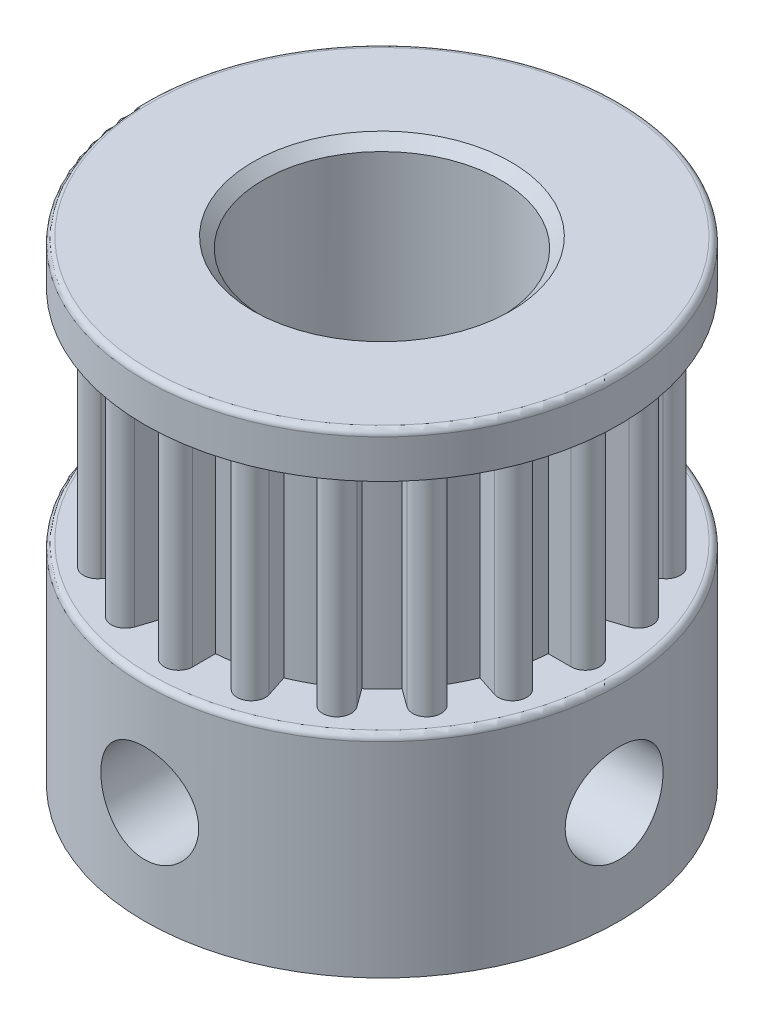
from build123d import *

# Parameters (mm, degrees)
SKETCH1_R           = 8
SKETCH1_R_2         = 6.11
SKETCH1_R_3         = 4
BOSS_EXTRUDE1_DEPTH = 7.1
SKETCH1_3_R         = 6.11
SKETCH1_3_R_2       = 4
BOSS_EXTRUDE2_DEPTH = 7.4
BOSS_EXTRUDE3_DEPTH = 7.4
SKETCH3_R           = 8
SKETCH3_R_2         = 4
BOSS_EXTRUDE4_DEPTH = 1.5
FILLET2_R           = 0.2
CHAMFER2_SIZE       = 0.35
CUT_EXTRUDE2_START  = -9.0000001
SKETCH5_R           = 1.65
CUT_EXTRUDE2_DEPTH  = 18.0000001
CIRPATTERN1_COUNT   = 2
CIRPATTERN1_ANGLE   = 90


with BuildPart() as part:
    # Sketch1 → Boss-Extrude1 (new body)
    with BuildSketch(Plane(origin=(0, 0, 0), x_dir=(1, 0, 0), z_dir=(0, 1, 0))):
        Circle(SKETCH1_R)
        Circle(SKETCH1_R_2, mode=Mode.SUBTRACT)
        Circle(SKETCH1_R_2)
        Circle(SKETCH1_R_3, mode=Mode.SUBTRACT)
    extrude(amount=-BOSS_EXTRUDE1_DEPTH)

    # Sketch1_3 → Boss-Extrude2 (add)
    with BuildSketch(Plane(origin=(0, 0, 0), x_dir=(1, 0, 0), z_dir=(0, 1, 0))):
        Circle(SKETCH1_3_R)
        Circle(SKETCH1_3_R_2, mode=Mode.SUBTRACT)
    extrude(amount=BOSS_EXTRUDE2_DEPTH)

    # Sketch2 → Boss-Extrude3 (add)
    with BuildSketch(Plane(origin=(0, 0, 0), x_dir=(1, 0, 0), z_dir=(0, 1, 0))):
        with BuildLine():
            Line((0.479878278, -6.86), (0.479878278, -6.091126073))
            ThreePointArc((0.479878278, -6.091126073), (0, -6.11), (-0.479878278, -6.091126073))
            Line((-0.479878278, -6.091126073), (-0.479878278, -6.86))
            ThreePointArc((-0.479878278, -6.86), (0, -7.339878278), (0.479878278, -6.86))
        make_face()
        with BuildLine():
            Line((-1.663465218, -6.672538245), (-1.425870108, -5.941295686))
            ThreePointArc((-1.425870108, -5.941295686), (-1.888093836, -5.810955315), (-2.338652835, -5.6447146))
            Line((-2.338652835, -5.6447146), (-2.576247945, -6.375957159))
            ThreePointArc((-2.576247945, -6.375957159), (-2.268147124, -6.980639065), (-1.663465218, -6.672538245))
        make_face()
        with BuildLine():
            Line((-3.643977149, -5.831921956), (-3.192044394, -5.209889883))
            ThreePointArc((-3.192044394, -5.209889883), (-3.591367892, -4.943093836), (-3.968503758, -4.645759133))
            Line((-3.968503758, -4.645759133), (-4.420436513, -5.267791207))
            ThreePointArc((-4.420436513, -5.267791207), (-4.314272205, -5.938086263), (-3.643977149, -5.831921956))
        make_face()
        with BuildLine():
            Line((-5.267791207, -4.420436513), (-4.645759133, -3.968503758))
            ThreePointArc((-4.645759133, -3.968503758), (-4.943093836, -3.591367892), (-5.209889883, -3.192044394))
            Line((-5.209889883, -3.192044394), (-5.831921956, -3.643977149))
            ThreePointArc((-5.831921956, -3.643977149), (-5.938086263, -4.314272205), (-5.267791207, -4.420436513))
        make_face()
        with BuildLine():
            Line((-6.375957159, -2.576247945), (-5.6447146, -2.338652835))
            ThreePointArc((-5.6447146, -2.338652835), (-5.810955315, -1.888093836), (-5.941295686, -1.425870108))
            Line((-5.941295686, -1.425870108), (-6.672538245, -1.663465218))
            ThreePointArc((-6.672538245, -1.663465218), (-6.980639065, -2.268147124), (-6.375957159, -2.576247945))
        make_face()
        with BuildLine():
            Line((-6.86, -0.479878278), (-6.091126073, -0.479878278))
            ThreePointArc((-6.091126073, -0.479878278), (-6.11, 0), (-6.091126073, 0.479878278))
            Line((-6.091126073, 0.479878278), (-6.86, 0.479878278))
            ThreePointArc((-6.86, 0.479878278), (-7.339878278, 0), (-6.86, -0.479878278))
        make_face()
        with BuildLine():
            Line((-6.672538245, 1.663465218), (-5.941295686, 1.425870108))
            ThreePointArc((-5.941295686, 1.425870108), (-5.810955315, 1.888093836), (-5.6447146, 2.338652835))
            Line((-5.6447146, 2.338652835), (-6.375957159, 2.576247945))
            ThreePointArc((-6.375957159, 2.576247945), (-6.980639065, 2.268147124), (-6.672538245, 1.663465218))
        make_face()
        with BuildLine():
            Line((-5.831921956, 3.643977149), (-5.209889883, 3.192044394))
            ThreePointArc((-5.209889883, 3.192044394), (-4.943093836, 3.591367892), (-4.645759133, 3.968503758))
            Line((-4.645759133, 3.968503758), (-5.267791207, 4.420436513))
            ThreePointArc((-5.267791207, 4.420436513), (-5.938086263, 4.314272205), (-5.831921956, 3.643977149))
        make_face()
        with BuildLine():
            Line((-4.420436513, 5.267791207), (-3.968503758, 4.645759133))
            ThreePointArc((-3.968503758, 4.645759133), (-3.591367892, 4.943093836), (-3.192044394, 5.209889883))
            Line((-3.192044394, 5.209889883), (-3.643977149, 5.831921956))
            ThreePointArc((-3.643977149, 5.831921956), (-4.314272205, 5.938086263), (-4.420436513, 5.267791207))
        make_face()
        with BuildLine():
            Line((-2.576247945, 6.375957159), (-2.338652835, 5.6447146))
            ThreePointArc((-2.338652835, 5.6447146), (-1.888093836, 5.810955315), (-1.425870108, 5.941295686))
            Line((-1.425870108, 5.941295686), (-1.663465218, 6.672538245))
            ThreePointArc((-1.663465218, 6.672538245), (-2.268147124, 6.980639065), (-2.576247945, 6.375957159))
        make_face()
        with BuildLine():
            Line((-0.479878278, 6.86), (-0.479878278, 6.091126073))
            ThreePointArc((-0.479878278, 6.091126073), (0, 6.11), (0.479878278, 6.091126073))
            Line((0.479878278, 6.091126073), (0.479878278, 6.86))
            ThreePointArc((0.479878278, 6.86), (0, 7.339878278), (-0.479878278, 6.86))
        make_face()
        with BuildLine():
            Line((1.663465218, 6.672538245), (1.425870108, 5.941295686))
            ThreePointArc((1.425870108, 5.941295686), (1.888093836, 5.810955315), (2.338652835, 5.6447146))
            Line((2.338652835, 5.6447146), (2.576247945, 6.375957159))
            ThreePointArc((2.576247945, 6.375957159), (2.268147124, 6.980639065), (1.663465218, 6.672538245))
        make_face()
        with BuildLine():
            Line((3.643977149, 5.831921956), (3.192044394, 5.209889883))
            ThreePointArc((3.192044394, 5.209889883), (3.591367892, 4.943093836), (3.968503758, 4.645759133))
            Line((3.968503758, 4.645759133), (4.420436513, 5.267791207))
            ThreePointArc((4.420436513, 5.267791207), (4.314272205, 5.938086263), (3.643977149, 5.831921956))
        make_face()
        with BuildLine():
            Line((5.267791207, 4.420436513), (4.645759133, 3.968503758))
            ThreePointArc((4.645759133, 3.968503758), (4.943093836, 3.591367892), (5.209889883, 3.192044394))
            Line((5.209889883, 3.192044394), (5.831921956, 3.643977149))
            ThreePointArc((5.831921956, 3.643977149), (5.938086263, 4.314272205), (5.267791207, 4.420436513))
        make_face()
        with BuildLine():
            Line((6.375957159, 2.576247945), (5.6447146, 2.338652835))
            ThreePointArc((5.6447146, 2.338652835), (5.810955315, 1.888093836), (5.941295686, 1.425870108))
            Line((5.941295686, 1.425870108), (6.672538245, 1.663465218))
            ThreePointArc((6.672538245, 1.663465218), (6.980639065, 2.268147124), (6.375957159, 2.576247945))
        make_face()
        with BuildLine():
            Line((6.86, 0.479878278), (6.091126073, 0.479878278))
            ThreePointArc((6.091126073, 0.479878278), (6.11, 0), (6.091126073, -0.479878278))
            Line((6.091126073, -0.479878278), (6.86, -0.479878278))
            ThreePointArc((6.86, -0.479878278), (7.339878278, 0), (6.86, 0.479878278))
        make_face()
        with BuildLine():
            Line((6.672538245, -1.663465218), (5.941295686, -1.425870108))
            ThreePointArc((5.941295686, -1.425870108), (5.810955315, -1.888093836), (5.6447146, -2.338652835))
            Line((5.6447146, -2.338652835), (6.375957159, -2.576247945))
            ThreePointArc((6.375957159, -2.576247945), (6.980639065, -2.268147124), (6.672538245, -1.663465218))
        make_face()
        with BuildLine():
            Line((5.831921956, -3.643977149), (5.209889883, -3.192044394))
            ThreePointArc((5.209889883, -3.192044394), (4.943093836, -3.591367892), (4.645759133, -3.968503758))
            Line((4.645759133, -3.968503758), (5.267791207, -4.420436513))
            ThreePointArc((5.267791207, -4.420436513), (5.938086263, -4.314272205), (5.831921956, -3.643977149))
        make_face()
        with BuildLine():
            Line((4.420436513, -5.267791207), (3.968503758, -4.645759133))
            ThreePointArc((3.968503758, -4.645759133), (3.591367892, -4.943093836), (3.192044394, -5.209889883))
            Line((3.192044394, -5.209889883), (3.643977149, -5.831921956))
            ThreePointArc((3.643977149, -5.831921956), (4.314272205, -5.938086263), (4.420436513, -5.267791207))
        make_face()
        with BuildLine():
            Line((2.576247945, -6.375957159), (2.338652835, -5.6447146))
            ThreePointArc((2.338652835, -5.6447146), (1.888093836, -5.810955315), (1.425870108, -5.941295686))
            Line((1.425870108, -5.941295686), (1.663465218, -6.672538245))
            ThreePointArc((1.663465218, -6.672538245), (2.268147124, -6.980639065), (2.576247945, -6.375957159))
        make_face()
    extrude(amount=BOSS_EXTRUDE3_DEPTH)

    # Sketch3 → Boss-Extrude4 (add)
    with BuildSketch(Plane(origin=(0, 7.4, 0), x_dir=(1, 0, 0), z_dir=(0, 1, 0))):
        Circle(SKETCH3_R)
        Circle(SKETCH3_R_2, mode=Mode.SUBTRACT)
    extrude(amount=BOSS_EXTRUDE4_DEPTH)

    # Fillet2
    fillet2_edges = [part.edges().sort_by_distance(p)[0] for p in [
        (-8, 8.9, 0),
        (-8, 0, 0),
    ]]
    fillet(fillet2_edges, radius=FILLET2_R)

    # Chamfer2
    chamfer2_edges = [part.edges().sort_by_distance(p)[0] for p in [
        (-4, 8.9, 0),
    ]]
    chamfer(chamfer2_edges, length=CHAMFER2_SIZE)

    # Sketch5 → Cut-Extrude2 (cut)
    with BuildSketch(Plane(origin=(0, 0, 0), x_dir=(0, 0, -1), z_dir=(1, 0, 0)).offset(CUT_EXTRUDE2_START)):
        with Locations((0, -3.65)):
            Circle(SKETCH5_R)
    cut_extrude2 = extrude(amount=CUT_EXTRUDE2_DEPTH, mode=Mode.SUBTRACT)

    # CirPattern1: Cut-Extrude2 ×2 about axis
    cirpattern1_axis = Axis((0, -7.1, 0), (0, 1, 0))
    for i in range(1, CIRPATTERN1_COUNT):
        add(cut_extrude2.rotate(cirpattern1_axis, i * CIRPATTERN1_ANGLE / (CIRPATTERN1_COUNT - 1)), mode=Mode.SUBTRACT)


solid = part.part
